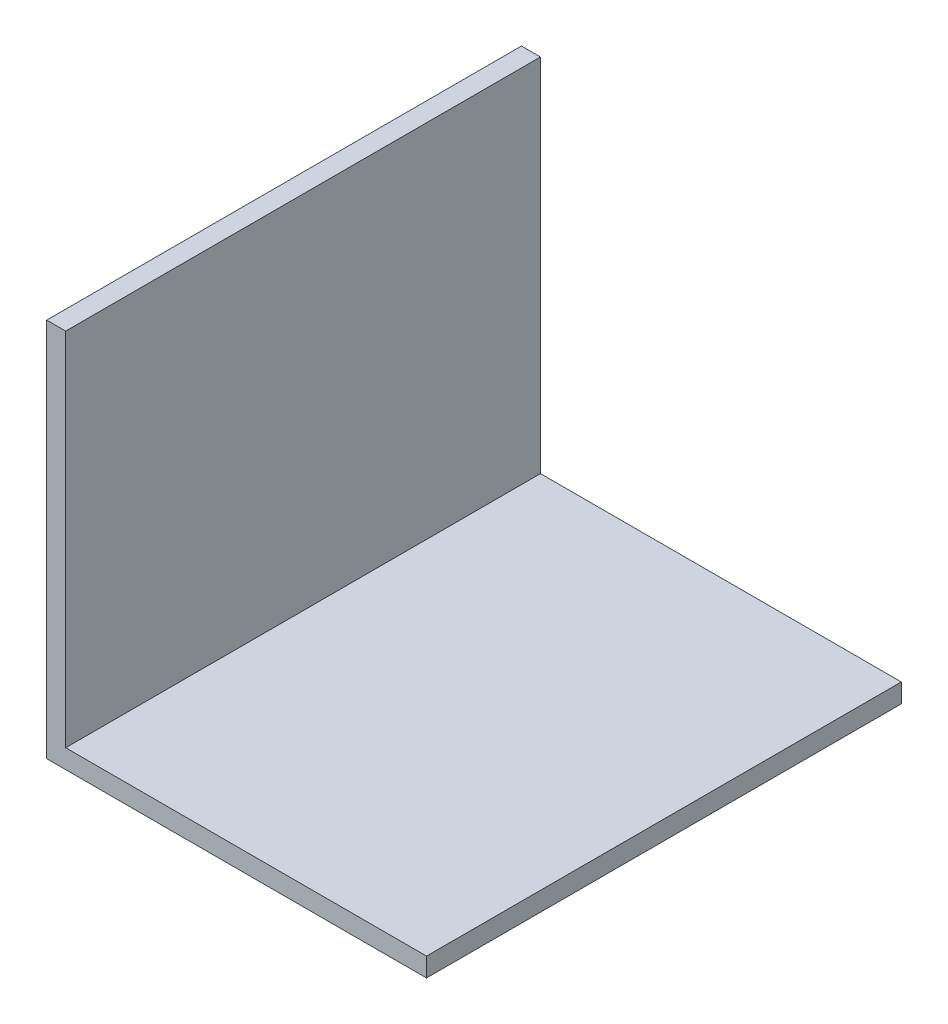
from build123d import *

# Parameters (mm, degrees)
BOSS_EXTRU_1_DEPTH = 50


with BuildPart() as part:
    # Esquisse1 → Boss.-Extru.1 (new body)
    with BuildSketch(Plane.XY):
        Polygon((0, 0), (40, 0), (40, 2), (2, 2), (2, 40), (0, 40), align=None)
    extrude(amount=BOSS_EXTRU_1_DEPTH)


solid = part.part
